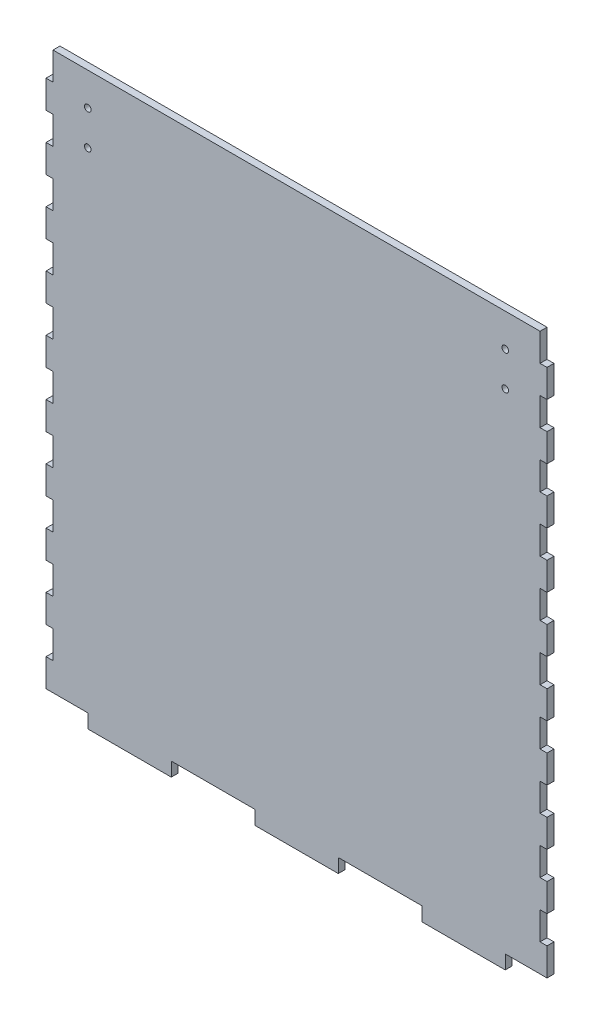
from build123d import *

# Parameters (mm, degrees)
BOSS_EXTRUDE1_DEPTH = 3.175
SKETCH3_R           = 1.5
CUT_EXTRUDE2_DEPTH  = 3.175


with BuildPart() as part:
    # Sketch1 → Boss-Extrude1 (new body)
    with BuildSketch(Plane.XY):
        Polygon((-111.125, 114.3), (-114.3, 114.3), (-114.3, 101.6), (-111.125, 101.6), (-111.125, 88.9), (-114.3, 88.9), (-114.3, 76.2), (-111.125, 76.2), (-111.125, 63.5), (-114.3, 63.5), (-114.3, 50.8), (-111.125, 50.8), (-111.125, 38.1), (-114.3, 38.1), (-114.3, 25.4), (-111.125, 25.4), (-111.125, 12.7), (-114.3, 12.7), (-114.3, 0), (-111.125, 0), (-111.125, -12.7), (-114.3, -12.7), (-114.3, -25.4), (-111.125, -25.4), (-111.125, -38.1), (-114.3, -38.1), (-114.3, -50.8), (-111.125, -50.8), (-111.125, -63.5), (-114.3, -63.5), (-114.3, -76.2), (-111.125, -76.2), (-111.125, -88.9), (-114.3, -88.9), (-114.3, -101.6), (-111.125, -101.6), (-111.125, -114.3), (-114.3, -114.3), (-114.3, -127), (-95.25, -127), (-95.25, -133.35), (-57.15, -133.35), (-57.15, -127), (-19.05, -127), (-19.05, -133.35), (19.05, -133.35), (19.05, -127), (57.15, -127), (57.15, -133.35), (95.25, -133.35), (95.25, -127), (114.3, -127), (114.3, -114.3), (111.125, -114.3), (111.125, -101.6), (114.3, -101.6), (114.3, -88.9), (111.125, -88.9), (111.125, -76.2), (114.3, -76.2), (114.3, -63.5), (111.125, -63.5), (111.125, -50.8), (114.3, -50.8), (114.3, -38.1), (111.125, -38.1), (111.125, -25.4), (114.3, -25.4), (114.3, -12.7), (111.125, -12.7), (111.125, 0), (114.3, 0), (114.3, 12.7), (111.125, 12.7), (111.125, 25.4), (114.3, 25.4), (114.3, 38.1), (111.125, 38.1), (111.125, 50.8), (114.3, 50.8), (114.3, 63.5), (111.125, 63.5), (111.125, 76.2), (114.3, 76.2), (114.3, 88.9), (111.125, 88.9), (111.125, 101.6), (114.3, 101.6), (114.3, 114.3), (111.125, 114.3), (111.125, 127), (-111.125, 127), align=None)
    extrude(amount=BOSS_EXTRUDE1_DEPTH)

    # Sketch3 → Cut-Extrude2 (cut)
    with BuildSketch(Plane(origin=(0, 0, 0), x_dir=(-1, 0, 0), z_dir=(0, 0, -1))):
        with Locations((-95.25, 112)):
            Circle(SKETCH3_R)
        with Locations((-95.25, 96.25)):
            Circle(SKETCH3_R)
        with Locations((95.25, 96.25)):
            Circle(SKETCH3_R)
        with Locations((95.25, 112)):
            Circle(SKETCH3_R)
    extrude(amount=-CUT_EXTRUDE2_DEPTH, mode=Mode.SUBTRACT)


solid = part.part
